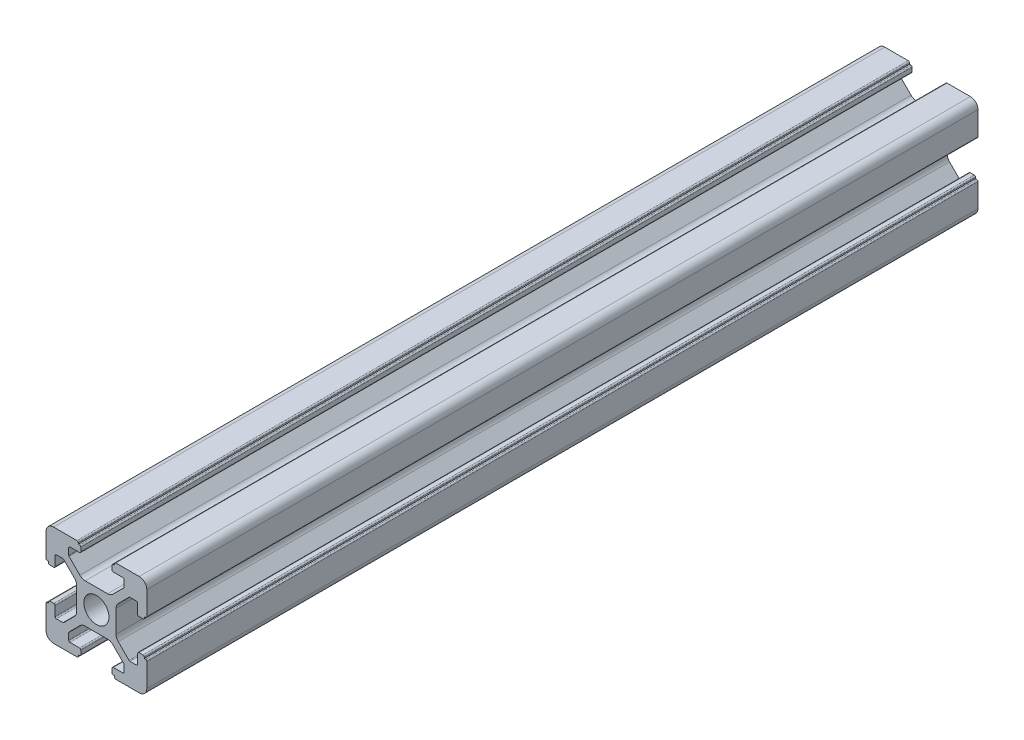
from build123d import *

# Parameters (mm, degrees)
SKETCH_1_R      = 2.5
EXTRUDE_1_DEPTH = 165


with BuildPart() as part:
    # 草图1 → 凸台-拉伸1 (new body)
    with BuildSketch(Plane.XY):
        with BuildLine():
            Line((-8.502261885, -10.002261885), (-3.85, -10.002261885))
            ThreePointArc((-3.85, -10.002261885), (-3.673223305, -9.929038581), (-3.6, -9.752261885))
            Line((-3.6, -9.752261885), (-3.6, -9.502261885))
            Line((-3.6, -9.502261885), (-3.35, -9.502261885))
            ThreePointArc((-3.35, -9.502261885), (-3.173223305, -9.429038581), (-3.1, -9.252261885))
            Line((-3.1, -9.252261885), (-3.1, -8.45))
            ThreePointArc((-3.1, -8.45), (-3.173223305, -8.273223305), (-3.35, -8.2))
            Line((-3.35, -8.2), (-5.25, -8.2))
            ThreePointArc((-5.25, -8.2), (-5.426776695, -8.126776695), (-5.5, -7.95))
            Line((-5.5, -7.95), (-5.5, -6.664213562))
            ThreePointArc((-5.5, -6.664213562), (-5.480969883, -6.568542704), (-5.426776695, -6.487436867))
            Line((-5.426776695, -6.487436867), (-3.278679656, -4.339339828))
            ThreePointArc((-3.278679656, -4.339339828), (-2.792044633, -4.014180701), (-2.218019485, -3.9))
            Line((-2.218019485, -3.9), (2.218019485, -3.9))
            ThreePointArc((2.218019485, -3.9), (2.792044633, -4.014180701), (3.278679656, -4.339339828))
            Line((3.278679656, -4.339339828), (5.426776695, -6.487436867))
            ThreePointArc((5.426776695, -6.487436867), (5.480969883, -6.568542704), (5.5, -6.664213562))
            Line((5.5, -6.664213562), (5.5, -7.95))
            ThreePointArc((5.5, -7.95), (5.426776695, -8.126776695), (5.25, -8.2))
            Line((5.25, -8.2), (3.35, -8.2))
            ThreePointArc((3.35, -8.2), (3.173223305, -8.273223305), (3.1, -8.45))
            Line((3.1, -8.45), (3.1, -9.252261885))
            ThreePointArc((3.1, -9.252261885), (3.173223305, -9.429038581), (3.35, -9.502261885))
            Line((3.35, -9.502261885), (3.6, -9.502261885))
            Line((3.6, -9.502261885), (3.6, -9.752261885))
            ThreePointArc((3.6, -9.752261885), (3.673223305, -9.929038581), (3.85, -10.002261885))
            Line((3.85, -10.002261885), (8.502261885, -10.002261885))
            ThreePointArc((8.502261885, -10.002261885), (9.562922057, -9.562922057), (10.002261885, -8.502261885))
            Line((10.002261885, -8.502261885), (10.002261885, -3.85))
            ThreePointArc((10.002261885, -3.85), (9.929038581, -3.673223305), (9.752261885, -3.6))
            Line((9.752261885, -3.6), (9.502261885, -3.6))
            Line((9.502261885, -3.6), (9.502261885, -3.35))
            ThreePointArc((9.502261885, -3.35), (9.429038581, -3.173223305), (9.252261885, -3.1))
            Line((9.252261885, -3.1), (8.45, -3.1))
            ThreePointArc((8.45, -3.1), (8.273223305, -3.173223305), (8.2, -3.35))
            Line((8.2, -3.35), (8.2, -5.25))
            ThreePointArc((8.2, -5.25), (8.126776695, -5.426776695), (7.95, -5.5))
            Line((7.95, -5.5), (6.664213562, -5.5))
            ThreePointArc((6.664213562, -5.5), (6.568542704, -5.480969883), (6.487436867, -5.426776695))
            Line((6.487436867, -5.426776695), (4.339339828, -3.278679656))
            ThreePointArc((4.339339828, -3.278679656), (4.014180701, -2.792044633), (3.9, -2.218019485))
            Line((3.9, -2.218019485), (3.9, 2.218019485))
            ThreePointArc((3.9, 2.218019485), (4.014180701, 2.792044633), (4.339339828, 3.278679656))
            Line((4.339339828, 3.278679656), (6.487436867, 5.426776695))
            ThreePointArc((6.487436867, 5.426776695), (6.568542704, 5.480969883), (6.664213562, 5.5))
            Line((6.664213562, 5.5), (7.95, 5.5))
            ThreePointArc((7.95, 5.5), (8.126776695, 5.426776695), (8.2, 5.25))
            Line((8.2, 5.25), (8.2, 3.35))
            ThreePointArc((8.2, 3.35), (8.273223305, 3.173223305), (8.45, 3.1))
            Line((8.45, 3.1), (9.252261885, 3.1))
            ThreePointArc((9.252261885, 3.1), (9.429038581, 3.173223305), (9.502261885, 3.35))
            Line((9.502261885, 3.35), (9.502261885, 3.6))
            Line((9.502261885, 3.6), (9.752261885, 3.6))
            ThreePointArc((9.752261885, 3.6), (9.929038581, 3.673223305), (10.002261885, 3.85))
            Line((10.002261885, 3.85), (10.002261885, 8.502261885))
            ThreePointArc((10.002261885, 8.502261885), (9.562922057, 9.562922057), (8.502261885, 10.002261885))
            Line((8.502261885, 10.002261885), (3.85, 10.002261885))
            ThreePointArc((3.85, 10.002261885), (3.673223305, 9.929038581), (3.6, 9.752261885))
            Line((3.6, 9.752261885), (3.6, 9.502261885))
            Line((3.6, 9.502261885), (3.35, 9.502261885))
            ThreePointArc((3.35, 9.502261885), (3.173223305, 9.429038581), (3.1, 9.252261885))
            Line((3.1, 9.252261885), (3.1, 8.45))
            ThreePointArc((3.1, 8.45), (3.173223305, 8.273223305), (3.35, 8.2))
            Line((3.35, 8.2), (5.25, 8.2))
            ThreePointArc((5.25, 8.2), (5.426776695, 8.126776695), (5.5, 7.95))
            Line((5.5, 7.95), (5.5, 6.664213562))
            ThreePointArc((5.5, 6.664213562), (5.480969883, 6.568542704), (5.426776695, 6.487436867))
            Line((5.426776695, 6.487436867), (3.278679656, 4.339339828))
            ThreePointArc((3.278679656, 4.339339828), (2.792044633, 4.014180701), (2.218019485, 3.9))
            Line((2.218019485, 3.9), (-2.218019485, 3.9))
            ThreePointArc((-2.218019485, 3.9), (-2.792044633, 4.014180701), (-3.278679656, 4.339339828))
            Line((-3.278679656, 4.339339828), (-5.426776695, 6.487436867))
            ThreePointArc((-5.426776695, 6.487436867), (-5.480969883, 6.568542704), (-5.5, 6.664213562))
            Line((-5.5, 6.664213562), (-5.5, 7.95))
            ThreePointArc((-5.5, 7.95), (-5.426776695, 8.126776695), (-5.25, 8.2))
            Line((-5.25, 8.2), (-3.35, 8.2))
            ThreePointArc((-3.35, 8.2), (-3.173223305, 8.273223305), (-3.1, 8.45))
            Line((-3.1, 8.45), (-3.1, 9.252261885))
            ThreePointArc((-3.1, 9.252261885), (-3.173223305, 9.429038581), (-3.35, 9.502261885))
            Line((-3.35, 9.502261885), (-3.6, 9.502261885))
            Line((-3.6, 9.502261885), (-3.6, 9.752261885))
            ThreePointArc((-3.6, 9.752261885), (-3.673223305, 9.929038581), (-3.85, 10.002261885))
            Line((-3.85, 10.002261885), (-8.502261885, 10.002261885))
            ThreePointArc((-8.502261885, 10.002261885), (-9.562922057, 9.562922057), (-10.002261885, 8.502261885))
            Line((-10.002261885, 8.502261885), (-10.002261885, 3.85))
            ThreePointArc((-10.002261885, 3.85), (-9.929038581, 3.673223305), (-9.752261885, 3.6))
            Line((-9.752261885, 3.6), (-9.502261885, 3.6))
            Line((-9.502261885, 3.6), (-9.502261885, 3.35))
            ThreePointArc((-9.502261885, 3.35), (-9.429038581, 3.173223305), (-9.252261885, 3.1))
            Line((-9.252261885, 3.1), (-8.45, 3.1))
            ThreePointArc((-8.45, 3.1), (-8.273223305, 3.173223305), (-8.2, 3.35))
            Line((-8.2, 3.35), (-8.2, 5.25))
            ThreePointArc((-8.2, 5.25), (-8.126776695, 5.426776695), (-7.95, 5.5))
            Line((-7.95, 5.5), (-6.664213562, 5.5))
            ThreePointArc((-6.664213562, 5.5), (-6.568542704, 5.480969883), (-6.487436867, 5.426776695))
            Line((-6.487436867, 5.426776695), (-4.339339828, 3.278679656))
            ThreePointArc((-4.339339828, 3.278679656), (-4.014180701, 2.792044633), (-3.9, 2.218019485))
            Line((-3.9, 2.218019485), (-3.9, -2.218019485))
            ThreePointArc((-3.9, -2.218019485), (-4.014180701, -2.792044633), (-4.339339828, -3.278679656))
            Line((-4.339339828, -3.278679656), (-6.487436867, -5.426776695))
            ThreePointArc((-6.487436867, -5.426776695), (-6.568542704, -5.480969883), (-6.664213562, -5.5))
            Line((-6.664213562, -5.5), (-7.95, -5.5))
            ThreePointArc((-7.95, -5.5), (-8.126776695, -5.426776695), (-8.2, -5.25))
            Line((-8.2, -5.25), (-8.2, -3.35))
            ThreePointArc((-8.2, -3.35), (-8.273223305, -3.173223305), (-8.45, -3.1))
            Line((-8.45, -3.1), (-9.252261885, -3.1))
            ThreePointArc((-9.252261885, -3.1), (-9.429038581, -3.173223305), (-9.502261885, -3.35))
            Line((-9.502261885, -3.35), (-9.502261885, -3.6))
            Line((-9.502261885, -3.6), (-9.752261885, -3.6))
            ThreePointArc((-9.752261885, -3.6), (-9.929038581, -3.673223305), (-10.002261885, -3.85))
            Line((-10.002261885, -3.85), (-10.002261885, -8.502261885))
            ThreePointArc((-10.002261885, -8.502261885), (-9.562922057, -9.562922057), (-8.502261885, -10.002261885))
        make_face()
        Circle(SKETCH_1_R, mode=Mode.SUBTRACT)
    extrude(amount=EXTRUDE_1_DEPTH)


solid = part.part
